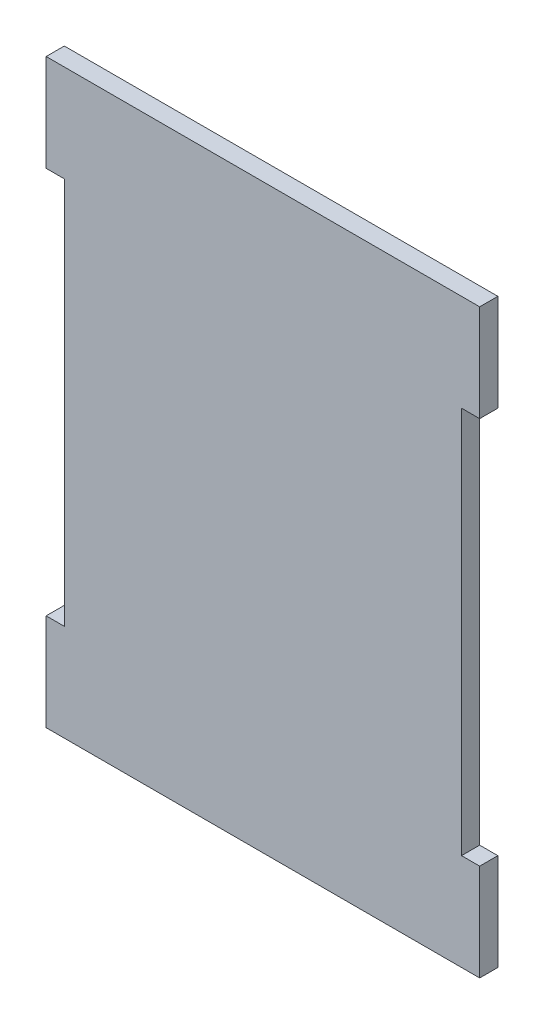
from build123d import *

# Parameters (mm, degrees)
BOSS_EXTRUDE1_DEPTH = 4.7625


with BuildPart() as part:
    # Sketch1 → Boss-Extrude1 (new body)
    with BuildSketch(Plane.XY):
        Polygon((4.7625, 108.395374669), (108.9025, 108.395374669), (113.665, 108.395374669), (113.665, 82.995374669), (108.9025, 82.995374669), (108.9025, -18.604625331), (113.665, -18.604625331), (113.665, -44.004625331), (108.9025, -44.004625331), (4.7625, -44.004625331), (0, -44.004625331), (0, -18.604625331), (4.7625, -18.604625331), (4.7625, 82.995374669), (0, 82.995374669), (0, 108.395374669), align=None)
    extrude(amount=BOSS_EXTRUDE1_DEPTH)


solid = part.part
